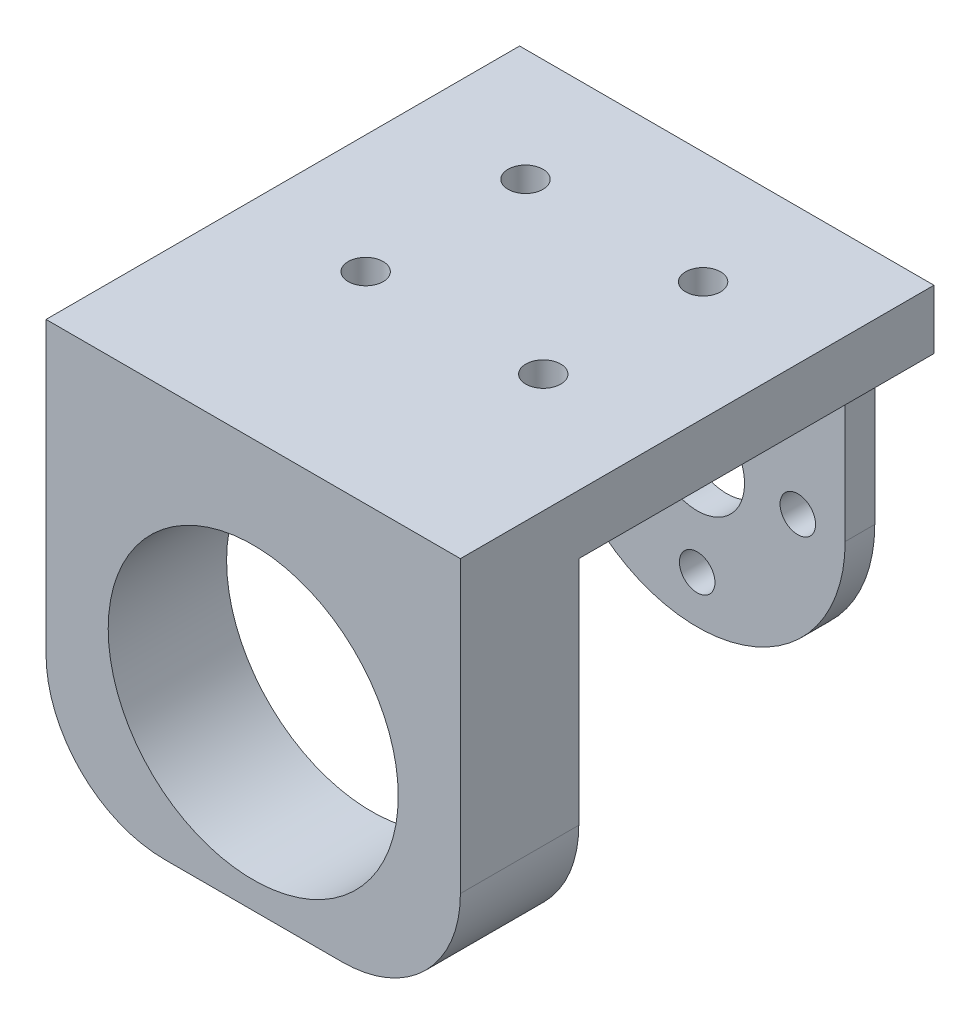
from build123d import *

# Parameters (mm, degrees)
SKETCH1_R           = 12.5
SKETCH1_R_2         = 4
BOSS_EXTRUDE1_DEPTH = 2.5
SKETCH2_W           = 25
SKETCH2_H           = 5
SKETCH2_W_2         = 5
BOSS_EXTRUDE3_DEPTH = 40
SKETCH3_W           = 35
SKETCH3_H           = 10
BOSS_EXTRUDE5_DEPTH = 29.5
SKETCH5_R           = 12.25
CUT_EXTRUDE1_DEPTH  = 29.5
SKETCH6_R           = 1.5
CUT_EXTRUDE2_DEPTH  = 29.5
SKETCH7_R           = 1.475
CUT_EXTRUDE4_DEPTH  = 10
SKETCH8_R           = 1.5
CUT_EXTRUDE5_DEPTH  = 10


with BuildPart() as part:
    # Sketch1 → Boss-Extrude1 (new body)
    with BuildSketch(Plane.XY):
        with BuildLine():
            Line((12.5, 20), (-12.5, 20))
            Line((-12.5, 20), (-12.5, 1.2e-08))
            ThreePointArc((-12.5, 1.2e-08), (6e-09, 12.5), (12.5, 0))
            Line((12.5, 0), (12.5, 20))
        make_face()
        Circle(SKETCH1_R)
        Circle(SKETCH1_R_2, mode=Mode.SUBTRACT)
    extrude(amount=BOSS_EXTRUDE1_DEPTH)

    # Sketch2 → Boss-Extrude3 (add)
    with BuildSketch(Plane(origin=(0, 0, 0), x_dir=(-1, 0, 0), z_dir=(0, 0, -1))):
        with Locations((0, 17.5)):
            Rectangle(SKETCH2_W, SKETCH2_H)
        with Locations((-15, 17.5)):
            Rectangle(SKETCH2_W_2, SKETCH2_H)
        with Locations((15, 17.5)):
            Rectangle(SKETCH2_W_2, SKETCH2_H)
    extrude(amount=-BOSS_EXTRUDE3_DEPTH)

    # Sketch3 → Boss-Extrude5 (add)
    with BuildSketch(Plane.XZ.offset(-15)):
        with Locations((0, 35)):
            Rectangle(SKETCH3_W, SKETCH3_H)
    extrude(amount=BOSS_EXTRUDE5_DEPTH)

    # Sketch5 → Cut-Extrude1 (cut)
    with BuildSketch(Plane(origin=(0, 0, 30), x_dir=(-1, 0, 0), z_dir=(0, 0, -1))):
        Circle(SKETCH5_R)
        with BuildLine():
            Line((17.5, -14.5), (17.5, -4.5))
            ThreePointArc((17.5, -4.5), (14.571067812, -11.571067812), (7.5, -14.5))
            Line((7.5, -14.5), (17.5, -14.5))
        make_face()
        with BuildLine():
            ThreePointArc((-7.5, -14.5), (-14.571067812, -11.571067812), (-17.5, -4.5))
            Line((-17.5, -4.5), (-17.5, -14.5))
            Line((-17.5, -14.5), (-7.5, -14.5))
        make_face()
    extrude(amount=-CUT_EXTRUDE1_DEPTH, mode=Mode.SUBTRACT)

    # Sketch6 → Cut-Extrude2 (cut)
    with BuildSketch(Plane(origin=(0, 0, 0), x_dir=(-1, 0, 0), z_dir=(0, 0, -1))):
        with Locations((0, 8.5)):
            Circle(SKETCH6_R)
        with Locations((0, -8.5)):
            Circle(SKETCH6_R)
    extrude(amount=-CUT_EXTRUDE2_DEPTH, mode=Mode.SUBTRACT)

    # Sketch7 → Cut-Extrude4 (cut)
    with BuildSketch(Plane.XZ.offset(-15)):
        with Locations((7.5, 23)):
            Circle(SKETCH7_R)
        with Locations((-7.5, 23)):
            Circle(SKETCH7_R)
        with Locations((7.5, 9.5)):
            Circle(SKETCH7_R)
        with Locations((-7.5, 9.5)):
            Circle(SKETCH7_R)
    extrude(amount=-CUT_EXTRUDE4_DEPTH, mode=Mode.SUBTRACT)

    # Sketch8 → Cut-Extrude5 (cut)
    with BuildSketch(Plane(origin=(0, 0, 0), x_dir=(-1, 0, 0), z_dir=(0, 0, -1))):
        with Locations((-8.5, 0)):
            Circle(SKETCH8_R)
        with Locations((8.5, 0)):
            Circle(SKETCH8_R)
    extrude(amount=-CUT_EXTRUDE5_DEPTH, mode=Mode.SUBTRACT)


solid = part.part
